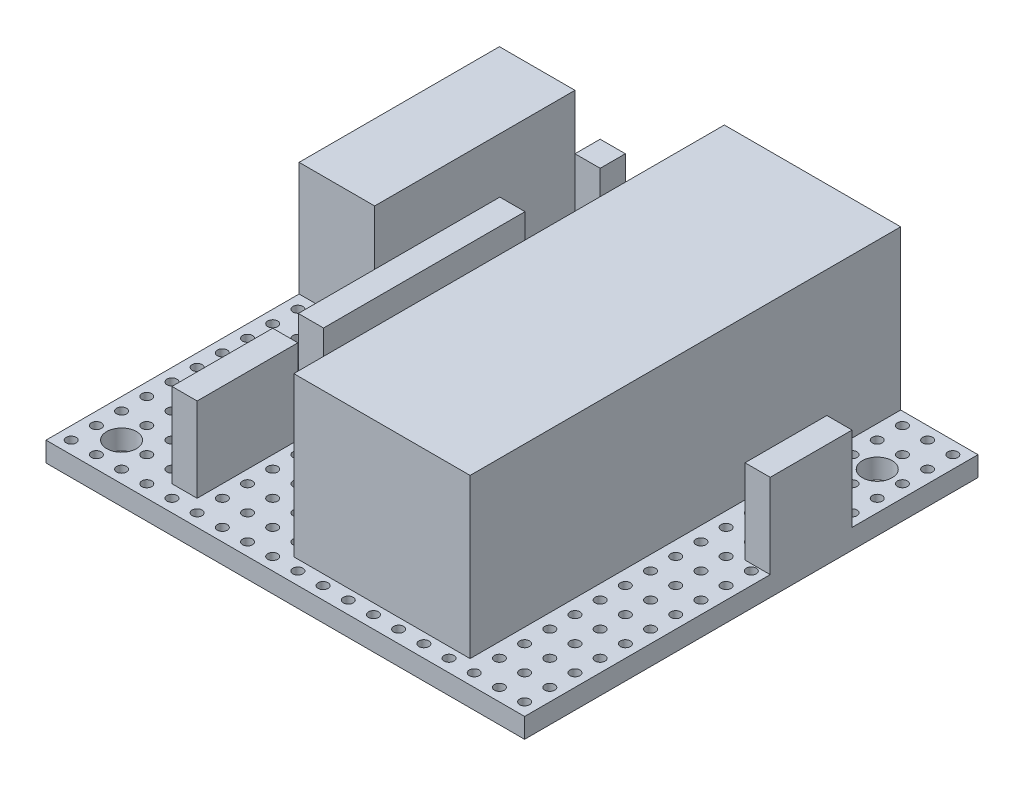
from build123d import *

# Parameters (mm, degrees)
SKETCH1_W               = 63.5
SKETCH1_H               = 45.72
SKETCH1_R               = 0.5
BOSS_EXTRUDE1_DEPTH     = 2
SKETCH4_W               = 15.24
SKETCH4_H               = 45.72
CUT_EXTRUDE1_DEPTH      = 1
CUT_EXTRUDE1_DEPTH_BACK = 3
SKETCH2_W               = 17.78
SKETCH2_H               = 43.418988053
BOSS_EXTRUDE2_DEPTH     = 16
SKETCH3_W               = 7.62
SKETCH3_H               = 20.2
BOSS_EXTRUDE3_DEPTH     = 11.5
SKETCH5_R               = 1.5
CUT_EXTRUDE2_DEPTH      = 17
CUT_EXTRUDE2_DEPTH_BACK = 3
SKETCH6_W               = 2.54
SKETCH6_H               = 10.16
SKETCH6_H_2             = 20.32
SKETCH6_H_3             = 2.54
SKETCH6_H_4             = 8.253316926
BOSS_EXTRUDE4_DEPTH     = 8.5


with BuildPart() as part:
    # Sketch1 → Boss-Extrude1 (new body)
    with BuildSketch(Plane(origin=(0, 0, 0), x_dir=(1, 0, 0), z_dir=(0, 1, 0))):
        with Locations((3.117422517, -7.111917277)):
            Rectangle(SKETCH1_W, SKETCH1_H)
        with Locations((33.597422517, -28.701917277)):
            Circle(SKETCH1_R, mode=Mode.SUBTRACT)
        with Locations((31.057422517, -28.701917277)):
            Circle(SKETCH1_R, mode=Mode.SUBTRACT)
        with Locations((28.517422517, -28.701917277)):
            Circle(SKETCH1_R, mode=Mode.SUBTRACT)
        with Locations((25.977422517, -28.701917277)):
            Circle(SKETCH1_R, mode=Mode.SUBTRACT)
        with Locations((23.437422517, -28.701917277)):
            Circle(SKETCH1_R, mode=Mode.SUBTRACT)
        with Locations((20.897422517, -28.701917277)):
            Circle(SKETCH1_R, mode=Mode.SUBTRACT)
        with Locations((18.357422517, -28.701917277)):
            Circle(SKETCH1_R, mode=Mode.SUBTRACT)
        with Locations((15.817422517, -28.701917277)):
            Circle(SKETCH1_R, mode=Mode.SUBTRACT)
        with Locations((13.277422517, -28.701917277)):
            Circle(SKETCH1_R, mode=Mode.SUBTRACT)
        with Locations((10.737422517, -28.701917277)):
            Circle(SKETCH1_R, mode=Mode.SUBTRACT)
        with Locations((8.197422517, -28.701917277)):
            Circle(SKETCH1_R, mode=Mode.SUBTRACT)
        with Locations((5.657422517, -28.701917277)):
            Circle(SKETCH1_R, mode=Mode.SUBTRACT)
        with Locations((3.117422517, -28.701917277)):
            Circle(SKETCH1_R, mode=Mode.SUBTRACT)
        with Locations((0.577422517, -28.701917277)):
            Circle(SKETCH1_R, mode=Mode.SUBTRACT)
        with Locations((-1.962577483, -28.701917277)):
            Circle(SKETCH1_R, mode=Mode.SUBTRACT)
        with Locations((-4.502577483, -28.701917277)):
            Circle(SKETCH1_R, mode=Mode.SUBTRACT)
        with Locations((-7.042577483, -28.701917277)):
            Circle(SKETCH1_R, mode=Mode.SUBTRACT)
        with Locations((-9.582577483, -28.701917277)):
            Circle(SKETCH1_R, mode=Mode.SUBTRACT)
        with Locations((-12.122577483, -28.701917277)):
            Circle(SKETCH1_R, mode=Mode.SUBTRACT)
        with Locations((-14.662577483, -28.701917277)):
            Circle(SKETCH1_R, mode=Mode.SUBTRACT)
        with Locations((-17.202577483, -28.701917277)):
            Circle(SKETCH1_R, mode=Mode.SUBTRACT)
        with Locations((-19.742577483, -28.701917277)):
            Circle(SKETCH1_R, mode=Mode.SUBTRACT)
        with Locations((-22.282577483, -28.701917277)):
            Circle(SKETCH1_R, mode=Mode.SUBTRACT)
        with Locations((-24.822577483, -28.701917277)):
            Circle(SKETCH1_R, mode=Mode.SUBTRACT)
        with Locations((-27.362577483, -28.701917277)):
            Circle(SKETCH1_R, mode=Mode.SUBTRACT)
        with Locations((31.057422517, -26.161917277)):
            Circle(SKETCH1_R, mode=Mode.SUBTRACT)
        with Locations((28.517422517, -26.161917277)):
            Circle(SKETCH1_R, mode=Mode.SUBTRACT)
        with Locations((25.977422517, -26.161917277)):
            Circle(SKETCH1_R, mode=Mode.SUBTRACT)
        with Locations((23.437422517, -26.161917277)):
            Circle(SKETCH1_R, mode=Mode.SUBTRACT)
        with Locations((20.897422517, -26.161917277)):
            Circle(SKETCH1_R, mode=Mode.SUBTRACT)
        with Locations((18.357422517, -26.161917277)):
            Circle(SKETCH1_R, mode=Mode.SUBTRACT)
        with Locations((15.817422517, -26.161917277)):
            Circle(SKETCH1_R, mode=Mode.SUBTRACT)
        with Locations((13.277422517, -26.161917277)):
            Circle(SKETCH1_R, mode=Mode.SUBTRACT)
        with Locations((10.737422517, -26.161917277)):
            Circle(SKETCH1_R, mode=Mode.SUBTRACT)
        with Locations((8.197422517, -26.161917277)):
            Circle(SKETCH1_R, mode=Mode.SUBTRACT)
        with Locations((5.657422517, -26.161917277)):
            Circle(SKETCH1_R, mode=Mode.SUBTRACT)
        with Locations((3.117422517, -26.161917277)):
            Circle(SKETCH1_R, mode=Mode.SUBTRACT)
        with Locations((0.577422517, -26.161917277)):
            Circle(SKETCH1_R, mode=Mode.SUBTRACT)
        with Locations((-1.962577483, -26.161917277)):
            Circle(SKETCH1_R, mode=Mode.SUBTRACT)
        with Locations((-4.502577483, -26.161917277)):
            Circle(SKETCH1_R, mode=Mode.SUBTRACT)
        with Locations((-7.042577483, -26.161917277)):
            Circle(SKETCH1_R, mode=Mode.SUBTRACT)
        with Locations((-9.582577483, -26.161917277)):
            Circle(SKETCH1_R, mode=Mode.SUBTRACT)
        with Locations((-12.122577483, -26.161917277)):
            Circle(SKETCH1_R, mode=Mode.SUBTRACT)
        with Locations((-14.662577483, -26.161917277)):
            Circle(SKETCH1_R, mode=Mode.SUBTRACT)
        with Locations((-17.202577483, -26.161917277)):
            Circle(SKETCH1_R, mode=Mode.SUBTRACT)
        with Locations((-19.742577483, -26.161917277)):
            Circle(SKETCH1_R, mode=Mode.SUBTRACT)
        with Locations((-22.282577483, -26.161917277)):
            Circle(SKETCH1_R, mode=Mode.SUBTRACT)
        with Locations((-24.822577483, -26.161917277)):
            Circle(SKETCH1_R, mode=Mode.SUBTRACT)
        with Locations((-27.362577483, -26.161917277)):
            Circle(SKETCH1_R, mode=Mode.SUBTRACT)
        with Locations((31.057422517, -23.621917277)):
            Circle(SKETCH1_R, mode=Mode.SUBTRACT)
        with Locations((28.517422517, -23.621917277)):
            Circle(SKETCH1_R, mode=Mode.SUBTRACT)
        with Locations((25.977422517, -23.621917277)):
            Circle(SKETCH1_R, mode=Mode.SUBTRACT)
        with Locations((23.437422517, -23.621917277)):
            Circle(SKETCH1_R, mode=Mode.SUBTRACT)
        with Locations((20.897422517, -23.621917277)):
            Circle(SKETCH1_R, mode=Mode.SUBTRACT)
        with Locations((18.357422517, -23.621917277)):
            Circle(SKETCH1_R, mode=Mode.SUBTRACT)
        with Locations((15.817422517, -23.621917277)):
            Circle(SKETCH1_R, mode=Mode.SUBTRACT)
        with Locations((13.277422517, -23.621917277)):
            Circle(SKETCH1_R, mode=Mode.SUBTRACT)
        with Locations((10.737422517, -23.621917277)):
            Circle(SKETCH1_R, mode=Mode.SUBTRACT)
        with Locations((8.197422517, -23.621917277)):
            Circle(SKETCH1_R, mode=Mode.SUBTRACT)
        with Locations((5.657422517, -23.621917277)):
            Circle(SKETCH1_R, mode=Mode.SUBTRACT)
        with Locations((3.117422517, -23.621917277)):
            Circle(SKETCH1_R, mode=Mode.SUBTRACT)
        with Locations((0.577422517, -23.621917277)):
            Circle(SKETCH1_R, mode=Mode.SUBTRACT)
        with Locations((-1.962577483, -23.621917277)):
            Circle(SKETCH1_R, mode=Mode.SUBTRACT)
        with Locations((-4.502577483, -23.621917277)):
            Circle(SKETCH1_R, mode=Mode.SUBTRACT)
        with Locations((-7.042577483, -23.621917277)):
            Circle(SKETCH1_R, mode=Mode.SUBTRACT)
        with Locations((-9.582577483, -23.621917277)):
            Circle(SKETCH1_R, mode=Mode.SUBTRACT)
        with Locations((-12.122577483, -23.621917277)):
            Circle(SKETCH1_R, mode=Mode.SUBTRACT)
        with Locations((-14.662577483, -23.621917277)):
            Circle(SKETCH1_R, mode=Mode.SUBTRACT)
        with Locations((-17.202577483, -23.621917277)):
            Circle(SKETCH1_R, mode=Mode.SUBTRACT)
        with Locations((-19.742577483, -23.621917277)):
            Circle(SKETCH1_R, mode=Mode.SUBTRACT)
        with Locations((-22.282577483, -23.621917277)):
            Circle(SKETCH1_R, mode=Mode.SUBTRACT)
        with Locations((-24.822577483, -23.621917277)):
            Circle(SKETCH1_R, mode=Mode.SUBTRACT)
        with Locations((-27.362577483, -23.621917277)):
            Circle(SKETCH1_R, mode=Mode.SUBTRACT)
        with Locations((31.057422517, -21.081917277)):
            Circle(SKETCH1_R, mode=Mode.SUBTRACT)
        with Locations((28.517422517, -21.081917277)):
            Circle(SKETCH1_R, mode=Mode.SUBTRACT)
        with Locations((25.977422517, -21.081917277)):
            Circle(SKETCH1_R, mode=Mode.SUBTRACT)
        with Locations((23.437422517, -21.081917277)):
            Circle(SKETCH1_R, mode=Mode.SUBTRACT)
        with Locations((20.897422517, -21.081917277)):
            Circle(SKETCH1_R, mode=Mode.SUBTRACT)
        with Locations((18.357422517, -21.081917277)):
            Circle(SKETCH1_R, mode=Mode.SUBTRACT)
        with Locations((15.817422517, -21.081917277)):
            Circle(SKETCH1_R, mode=Mode.SUBTRACT)
        with Locations((13.277422517, -21.081917277)):
            Circle(SKETCH1_R, mode=Mode.SUBTRACT)
        with Locations((10.737422517, -21.081917277)):
            Circle(SKETCH1_R, mode=Mode.SUBTRACT)
        with Locations((8.197422517, -21.081917277)):
            Circle(SKETCH1_R, mode=Mode.SUBTRACT)
        with Locations((5.657422517, -21.081917277)):
            Circle(SKETCH1_R, mode=Mode.SUBTRACT)
        with Locations((3.117422517, -21.081917277)):
            Circle(SKETCH1_R, mode=Mode.SUBTRACT)
        with Locations((0.577422517, -21.081917277)):
            Circle(SKETCH1_R, mode=Mode.SUBTRACT)
        with Locations((-1.962577483, -21.081917277)):
            Circle(SKETCH1_R, mode=Mode.SUBTRACT)
        with Locations((-4.502577483, -21.081917277)):
            Circle(SKETCH1_R, mode=Mode.SUBTRACT)
        with Locations((-7.042577483, -21.081917277)):
            Circle(SKETCH1_R, mode=Mode.SUBTRACT)
        with Locations((-9.582577483, -21.081917277)):
            Circle(SKETCH1_R, mode=Mode.SUBTRACT)
        with Locations((-12.122577483, -21.081917277)):
            Circle(SKETCH1_R, mode=Mode.SUBTRACT)
        with Locations((-14.662577483, -21.081917277)):
            Circle(SKETCH1_R, mode=Mode.SUBTRACT)
        with Locations((-17.202577483, -21.081917277)):
            Circle(SKETCH1_R, mode=Mode.SUBTRACT)
        with Locations((-19.742577483, -21.081917277)):
            Circle(SKETCH1_R, mode=Mode.SUBTRACT)
        with Locations((-22.282577483, -21.081917277)):
            Circle(SKETCH1_R, mode=Mode.SUBTRACT)
        with Locations((-24.822577483, -21.081917277)):
            Circle(SKETCH1_R, mode=Mode.SUBTRACT)
        with Locations((-27.362577483, -21.081917277)):
            Circle(SKETCH1_R, mode=Mode.SUBTRACT)
        with Locations((31.057422517, -18.541917277)):
            Circle(SKETCH1_R, mode=Mode.SUBTRACT)
        with Locations((28.517422517, -18.541917277)):
            Circle(SKETCH1_R, mode=Mode.SUBTRACT)
        with Locations((25.977422517, -18.541917277)):
            Circle(SKETCH1_R, mode=Mode.SUBTRACT)
        with Locations((23.437422517, -18.541917277)):
            Circle(SKETCH1_R, mode=Mode.SUBTRACT)
        with Locations((20.897422517, -18.541917277)):
            Circle(SKETCH1_R, mode=Mode.SUBTRACT)
        with Locations((18.357422517, -18.541917277)):
            Circle(SKETCH1_R, mode=Mode.SUBTRACT)
        with Locations((15.817422517, -18.541917277)):
            Circle(SKETCH1_R, mode=Mode.SUBTRACT)
        with Locations((13.277422517, -18.541917277)):
            Circle(SKETCH1_R, mode=Mode.SUBTRACT)
        with Locations((10.737422517, -18.541917277)):
            Circle(SKETCH1_R, mode=Mode.SUBTRACT)
        with Locations((8.197422517, -18.541917277)):
            Circle(SKETCH1_R, mode=Mode.SUBTRACT)
        with Locations((5.657422517, -18.541917277)):
            Circle(SKETCH1_R, mode=Mode.SUBTRACT)
        with Locations((3.117422517, -18.541917277)):
            Circle(SKETCH1_R, mode=Mode.SUBTRACT)
        with Locations((0.577422517, -18.541917277)):
            Circle(SKETCH1_R, mode=Mode.SUBTRACT)
        with Locations((-1.962577483, -18.541917277)):
            Circle(SKETCH1_R, mode=Mode.SUBTRACT)
        with Locations((-4.502577483, -18.541917277)):
            Circle(SKETCH1_R, mode=Mode.SUBTRACT)
        with Locations((-7.042577483, -18.541917277)):
            Circle(SKETCH1_R, mode=Mode.SUBTRACT)
        with Locations((-9.582577483, -18.541917277)):
            Circle(SKETCH1_R, mode=Mode.SUBTRACT)
        with Locations((-12.122577483, -18.541917277)):
            Circle(SKETCH1_R, mode=Mode.SUBTRACT)
        with Locations((-14.662577483, -18.541917277)):
            Circle(SKETCH1_R, mode=Mode.SUBTRACT)
        with Locations((-17.202577483, -18.541917277)):
            Circle(SKETCH1_R, mode=Mode.SUBTRACT)
        with Locations((-19.742577483, -18.541917277)):
            Circle(SKETCH1_R, mode=Mode.SUBTRACT)
        with Locations((-22.282577483, -18.541917277)):
            Circle(SKETCH1_R, mode=Mode.SUBTRACT)
        with Locations((-24.822577483, -18.541917277)):
            Circle(SKETCH1_R, mode=Mode.SUBTRACT)
        with Locations((-27.362577483, -18.541917277)):
            Circle(SKETCH1_R, mode=Mode.SUBTRACT)
        with Locations((31.057422517, -16.001917277)):
            Circle(SKETCH1_R, mode=Mode.SUBTRACT)
        with Locations((28.517422517, -16.001917277)):
            Circle(SKETCH1_R, mode=Mode.SUBTRACT)
        with Locations((25.977422517, -16.001917277)):
            Circle(SKETCH1_R, mode=Mode.SUBTRACT)
        with Locations((23.437422517, -16.001917277)):
            Circle(SKETCH1_R, mode=Mode.SUBTRACT)
        with Locations((20.897422517, -16.001917277)):
            Circle(SKETCH1_R, mode=Mode.SUBTRACT)
        with Locations((18.357422517, -16.001917277)):
            Circle(SKETCH1_R, mode=Mode.SUBTRACT)
        with Locations((15.817422517, -16.001917277)):
            Circle(SKETCH1_R, mode=Mode.SUBTRACT)
        with Locations((13.277422517, -16.001917277)):
            Circle(SKETCH1_R, mode=Mode.SUBTRACT)
        with Locations((10.737422517, -16.001917277)):
            Circle(SKETCH1_R, mode=Mode.SUBTRACT)
        with Locations((8.197422517, -16.001917277)):
            Circle(SKETCH1_R, mode=Mode.SUBTRACT)
        with Locations((5.657422517, -16.001917277)):
            Circle(SKETCH1_R, mode=Mode.SUBTRACT)
        with Locations((3.117422517, -16.001917277)):
            Circle(SKETCH1_R, mode=Mode.SUBTRACT)
        with Locations((0.577422517, -16.001917277)):
            Circle(SKETCH1_R, mode=Mode.SUBTRACT)
        with Locations((-1.962577483, -16.001917277)):
            Circle(SKETCH1_R, mode=Mode.SUBTRACT)
        with Locations((-4.502577483, -16.001917277)):
            Circle(SKETCH1_R, mode=Mode.SUBTRACT)
        with Locations((-7.042577483, -16.001917277)):
            Circle(SKETCH1_R, mode=Mode.SUBTRACT)
        with Locations((-9.582577483, -16.001917277)):
            Circle(SKETCH1_R, mode=Mode.SUBTRACT)
        with Locations((-12.122577483, -16.001917277)):
            Circle(SKETCH1_R, mode=Mode.SUBTRACT)
        with Locations((-14.662577483, -16.001917277)):
            Circle(SKETCH1_R, mode=Mode.SUBTRACT)
        with Locations((-17.202577483, -16.001917277)):
            Circle(SKETCH1_R, mode=Mode.SUBTRACT)
        with Locations((-19.742577483, -16.001917277)):
            Circle(SKETCH1_R, mode=Mode.SUBTRACT)
        with Locations((-22.282577483, -16.001917277)):
            Circle(SKETCH1_R, mode=Mode.SUBTRACT)
        with Locations((-24.822577483, -16.001917277)):
            Circle(SKETCH1_R, mode=Mode.SUBTRACT)
        with Locations((-27.362577483, -16.001917277)):
            Circle(SKETCH1_R, mode=Mode.SUBTRACT)
        with Locations((31.057422517, -13.461917277)):
            Circle(SKETCH1_R, mode=Mode.SUBTRACT)
        with Locations((28.517422517, -13.461917277)):
            Circle(SKETCH1_R, mode=Mode.SUBTRACT)
        with Locations((25.977422517, -13.461917277)):
            Circle(SKETCH1_R, mode=Mode.SUBTRACT)
        with Locations((23.437422517, -13.461917277)):
            Circle(SKETCH1_R, mode=Mode.SUBTRACT)
        with Locations((20.897422517, -13.461917277)):
            Circle(SKETCH1_R, mode=Mode.SUBTRACT)
        with Locations((18.357422517, -13.461917277)):
            Circle(SKETCH1_R, mode=Mode.SUBTRACT)
        with Locations((15.817422517, -13.461917277)):
            Circle(SKETCH1_R, mode=Mode.SUBTRACT)
        with Locations((13.277422517, -13.461917277)):
            Circle(SKETCH1_R, mode=Mode.SUBTRACT)
        with Locations((10.737422517, -13.461917277)):
            Circle(SKETCH1_R, mode=Mode.SUBTRACT)
        with Locations((8.197422517, -13.461917277)):
            Circle(SKETCH1_R, mode=Mode.SUBTRACT)
        with Locations((5.657422517, -13.461917277)):
            Circle(SKETCH1_R, mode=Mode.SUBTRACT)
        with Locations((3.117422517, -13.461917277)):
            Circle(SKETCH1_R, mode=Mode.SUBTRACT)
        with Locations((0.577422517, -13.461917277)):
            Circle(SKETCH1_R, mode=Mode.SUBTRACT)
        with Locations((-1.962577483, -13.461917277)):
            Circle(SKETCH1_R, mode=Mode.SUBTRACT)
        with Locations((-4.502577483, -13.461917277)):
            Circle(SKETCH1_R, mode=Mode.SUBTRACT)
        with Locations((-7.042577483, -13.461917277)):
            Circle(SKETCH1_R, mode=Mode.SUBTRACT)
        with Locations((-9.582577483, -13.461917277)):
            Circle(SKETCH1_R, mode=Mode.SUBTRACT)
        with Locations((-12.122577483, -13.461917277)):
            Circle(SKETCH1_R, mode=Mode.SUBTRACT)
        with Locations((-14.662577483, -13.461917277)):
            Circle(SKETCH1_R, mode=Mode.SUBTRACT)
        with Locations((-17.202577483, -13.461917277)):
            Circle(SKETCH1_R, mode=Mode.SUBTRACT)
        with Locations((-19.742577483, -13.461917277)):
            Circle(SKETCH1_R, mode=Mode.SUBTRACT)
        with Locations((-22.282577483, -13.461917277)):
            Circle(SKETCH1_R, mode=Mode.SUBTRACT)
        with Locations((-24.822577483, -13.461917277)):
            Circle(SKETCH1_R, mode=Mode.SUBTRACT)
        with Locations((-27.362577483, -13.461917277)):
            Circle(SKETCH1_R, mode=Mode.SUBTRACT)
        with Locations((31.057422517, -10.921917277)):
            Circle(SKETCH1_R, mode=Mode.SUBTRACT)
        with Locations((28.517422517, -10.921917277)):
            Circle(SKETCH1_R, mode=Mode.SUBTRACT)
        with Locations((25.977422517, -10.921917277)):
            Circle(SKETCH1_R, mode=Mode.SUBTRACT)
        with Locations((23.437422517, -10.921917277)):
            Circle(SKETCH1_R, mode=Mode.SUBTRACT)
        with Locations((20.897422517, -10.921917277)):
            Circle(SKETCH1_R, mode=Mode.SUBTRACT)
        with Locations((18.357422517, -10.921917277)):
            Circle(SKETCH1_R, mode=Mode.SUBTRACT)
        with Locations((15.817422517, -10.921917277)):
            Circle(SKETCH1_R, mode=Mode.SUBTRACT)
        with Locations((13.277422517, -10.921917277)):
            Circle(SKETCH1_R, mode=Mode.SUBTRACT)
        with Locations((10.737422517, -10.921917277)):
            Circle(SKETCH1_R, mode=Mode.SUBTRACT)
        with Locations((8.197422517, -10.921917277)):
            Circle(SKETCH1_R, mode=Mode.SUBTRACT)
        with Locations((5.657422517, -10.921917277)):
            Circle(SKETCH1_R, mode=Mode.SUBTRACT)
        with Locations((3.117422517, -10.921917277)):
            Circle(SKETCH1_R, mode=Mode.SUBTRACT)
        with Locations((0.577422517, -10.921917277)):
            Circle(SKETCH1_R, mode=Mode.SUBTRACT)
        with Locations((-1.962577483, -10.921917277)):
            Circle(SKETCH1_R, mode=Mode.SUBTRACT)
        with Locations((-4.502577483, -10.921917277)):
            Circle(SKETCH1_R, mode=Mode.SUBTRACT)
        with Locations((-7.042577483, -10.921917277)):
            Circle(SKETCH1_R, mode=Mode.SUBTRACT)
        with Locations((-9.582577483, -10.921917277)):
            Circle(SKETCH1_R, mode=Mode.SUBTRACT)
        with Locations((-12.122577483, -10.921917277)):
            Circle(SKETCH1_R, mode=Mode.SUBTRACT)
        with Locations((-14.662577483, -10.921917277)):
            Circle(SKETCH1_R, mode=Mode.SUBTRACT)
        with Locations((-17.202577483, -10.921917277)):
            Circle(SKETCH1_R, mode=Mode.SUBTRACT)
        with Locations((-19.742577483, -10.921917277)):
            Circle(SKETCH1_R, mode=Mode.SUBTRACT)
        with Locations((-22.282577483, -10.921917277)):
            Circle(SKETCH1_R, mode=Mode.SUBTRACT)
        with Locations((-24.822577483, -10.921917277)):
            Circle(SKETCH1_R, mode=Mode.SUBTRACT)
        with Locations((-27.362577483, -10.921917277)):
            Circle(SKETCH1_R, mode=Mode.SUBTRACT)
        with Locations((31.057422517, -8.381917277)):
            Circle(SKETCH1_R, mode=Mode.SUBTRACT)
        with Locations((28.517422517, -8.381917277)):
            Circle(SKETCH1_R, mode=Mode.SUBTRACT)
        with Locations((25.977422517, -8.381917277)):
            Circle(SKETCH1_R, mode=Mode.SUBTRACT)
        with Locations((23.437422517, -8.381917277)):
            Circle(SKETCH1_R, mode=Mode.SUBTRACT)
        with Locations((20.897422517, -8.381917277)):
            Circle(SKETCH1_R, mode=Mode.SUBTRACT)
        with Locations((18.357422517, -8.381917277)):
            Circle(SKETCH1_R, mode=Mode.SUBTRACT)
        with Locations((15.817422517, -8.381917277)):
            Circle(SKETCH1_R, mode=Mode.SUBTRACT)
        with Locations((13.277422517, -8.381917277)):
            Circle(SKETCH1_R, mode=Mode.SUBTRACT)
        with Locations((10.737422517, -8.381917277)):
            Circle(SKETCH1_R, mode=Mode.SUBTRACT)
        with Locations((8.197422517, -8.381917277)):
            Circle(SKETCH1_R, mode=Mode.SUBTRACT)
        with Locations((5.657422517, -8.381917277)):
            Circle(SKETCH1_R, mode=Mode.SUBTRACT)
        with Locations((3.117422517, -8.381917277)):
            Circle(SKETCH1_R, mode=Mode.SUBTRACT)
        with Locations((0.577422517, -8.381917277)):
            Circle(SKETCH1_R, mode=Mode.SUBTRACT)
        with Locations((-1.962577483, -8.381917277)):
            Circle(SKETCH1_R, mode=Mode.SUBTRACT)
        with Locations((-4.502577483, -8.381917277)):
            Circle(SKETCH1_R, mode=Mode.SUBTRACT)
        with Locations((-7.042577483, -8.381917277)):
            Circle(SKETCH1_R, mode=Mode.SUBTRACT)
        with Locations((-9.582577483, -8.381917277)):
            Circle(SKETCH1_R, mode=Mode.SUBTRACT)
        with Locations((-12.122577483, -8.381917277)):
            Circle(SKETCH1_R, mode=Mode.SUBTRACT)
        with Locations((-14.662577483, -8.381917277)):
            Circle(SKETCH1_R, mode=Mode.SUBTRACT)
        with Locations((-17.202577483, -8.381917277)):
            Circle(SKETCH1_R, mode=Mode.SUBTRACT)
        with Locations((-19.742577483, -8.381917277)):
            Circle(SKETCH1_R, mode=Mode.SUBTRACT)
        with Locations((-22.282577483, -8.381917277)):
            Circle(SKETCH1_R, mode=Mode.SUBTRACT)
        with Locations((-24.822577483, -8.381917277)):
            Circle(SKETCH1_R, mode=Mode.SUBTRACT)
        with Locations((-27.362577483, -8.381917277)):
            Circle(SKETCH1_R, mode=Mode.SUBTRACT)
        with Locations((31.057422517, -5.841917277)):
            Circle(SKETCH1_R, mode=Mode.SUBTRACT)
        with Locations((28.517422517, -5.841917277)):
            Circle(SKETCH1_R, mode=Mode.SUBTRACT)
        with Locations((25.977422517, -5.841917277)):
            Circle(SKETCH1_R, mode=Mode.SUBTRACT)
        with Locations((23.437422517, -5.841917277)):
            Circle(SKETCH1_R, mode=Mode.SUBTRACT)
        with Locations((20.897422517, -5.841917277)):
            Circle(SKETCH1_R, mode=Mode.SUBTRACT)
        with Locations((18.357422517, -5.841917277)):
            Circle(SKETCH1_R, mode=Mode.SUBTRACT)
        with Locations((15.817422517, -5.841917277)):
            Circle(SKETCH1_R, mode=Mode.SUBTRACT)
        with Locations((13.277422517, -5.841917277)):
            Circle(SKETCH1_R, mode=Mode.SUBTRACT)
        with Locations((10.737422517, -5.841917277)):
            Circle(SKETCH1_R, mode=Mode.SUBTRACT)
        with Locations((8.197422517, -5.841917277)):
            Circle(SKETCH1_R, mode=Mode.SUBTRACT)
        with Locations((5.657422517, -5.841917277)):
            Circle(SKETCH1_R, mode=Mode.SUBTRACT)
        with Locations((3.117422517, -5.841917277)):
            Circle(SKETCH1_R, mode=Mode.SUBTRACT)
        with Locations((0.577422517, -5.841917277)):
            Circle(SKETCH1_R, mode=Mode.SUBTRACT)
        with Locations((-1.962577483, -5.841917277)):
            Circle(SKETCH1_R, mode=Mode.SUBTRACT)
        with Locations((-4.502577483, -5.841917277)):
            Circle(SKETCH1_R, mode=Mode.SUBTRACT)
        with Locations((-7.042577483, -5.841917277)):
            Circle(SKETCH1_R, mode=Mode.SUBTRACT)
        with Locations((-9.582577483, -5.841917277)):
            Circle(SKETCH1_R, mode=Mode.SUBTRACT)
        with Locations((-12.122577483, -5.841917277)):
            Circle(SKETCH1_R, mode=Mode.SUBTRACT)
        with Locations((-14.662577483, -5.841917277)):
            Circle(SKETCH1_R, mode=Mode.SUBTRACT)
        with Locations((-17.202577483, -5.841917277)):
            Circle(SKETCH1_R, mode=Mode.SUBTRACT)
        with Locations((-19.742577483, -5.841917277)):
            Circle(SKETCH1_R, mode=Mode.SUBTRACT)
        with Locations((-22.282577483, -5.841917277)):
            Circle(SKETCH1_R, mode=Mode.SUBTRACT)
        with Locations((-24.822577483, -5.841917277)):
            Circle(SKETCH1_R, mode=Mode.SUBTRACT)
        with Locations((-27.362577483, -5.841917277)):
            Circle(SKETCH1_R, mode=Mode.SUBTRACT)
        with Locations((31.057422517, -3.301917277)):
            Circle(SKETCH1_R, mode=Mode.SUBTRACT)
        with Locations((28.517422517, -3.301917277)):
            Circle(SKETCH1_R, mode=Mode.SUBTRACT)
        with Locations((25.977422517, -3.301917277)):
            Circle(SKETCH1_R, mode=Mode.SUBTRACT)
        with Locations((23.437422517, -3.301917277)):
            Circle(SKETCH1_R, mode=Mode.SUBTRACT)
        with Locations((20.897422517, -3.301917277)):
            Circle(SKETCH1_R, mode=Mode.SUBTRACT)
        with Locations((18.357422517, -3.301917277)):
            Circle(SKETCH1_R, mode=Mode.SUBTRACT)
        with Locations((15.817422517, -3.301917277)):
            Circle(SKETCH1_R, mode=Mode.SUBTRACT)
        with Locations((13.277422517, -3.301917277)):
            Circle(SKETCH1_R, mode=Mode.SUBTRACT)
        with Locations((10.737422517, -3.301917277)):
            Circle(SKETCH1_R, mode=Mode.SUBTRACT)
        with Locations((8.197422517, -3.301917277)):
            Circle(SKETCH1_R, mode=Mode.SUBTRACT)
        with Locations((5.657422517, -3.301917277)):
            Circle(SKETCH1_R, mode=Mode.SUBTRACT)
        with Locations((3.117422517, -3.301917277)):
            Circle(SKETCH1_R, mode=Mode.SUBTRACT)
        with Locations((0.577422517, -3.301917277)):
            Circle(SKETCH1_R, mode=Mode.SUBTRACT)
        with Locations((-1.962577483, -3.301917277)):
            Circle(SKETCH1_R, mode=Mode.SUBTRACT)
        with Locations((-4.502577483, -3.301917277)):
            Circle(SKETCH1_R, mode=Mode.SUBTRACT)
        with Locations((-7.042577483, -3.301917277)):
            Circle(SKETCH1_R, mode=Mode.SUBTRACT)
        with Locations((-9.582577483, -3.301917277)):
            Circle(SKETCH1_R, mode=Mode.SUBTRACT)
        with Locations((-12.122577483, -3.301917277)):
            Circle(SKETCH1_R, mode=Mode.SUBTRACT)
        with Locations((-14.662577483, -3.301917277)):
            Circle(SKETCH1_R, mode=Mode.SUBTRACT)
        with Locations((-17.202577483, -3.301917277)):
            Circle(SKETCH1_R, mode=Mode.SUBTRACT)
        with Locations((-19.742577483, -3.301917277)):
            Circle(SKETCH1_R, mode=Mode.SUBTRACT)
        with Locations((-22.282577483, -3.301917277)):
            Circle(SKETCH1_R, mode=Mode.SUBTRACT)
        with Locations((-24.822577483, -3.301917277)):
            Circle(SKETCH1_R, mode=Mode.SUBTRACT)
        with Locations((-27.362577483, -3.301917277)):
            Circle(SKETCH1_R, mode=Mode.SUBTRACT)
        with Locations((31.057422517, -0.761917277)):
            Circle(SKETCH1_R, mode=Mode.SUBTRACT)
        with Locations((28.517422517, -0.761917277)):
            Circle(SKETCH1_R, mode=Mode.SUBTRACT)
        with Locations((25.977422517, -0.761917277)):
            Circle(SKETCH1_R, mode=Mode.SUBTRACT)
        with Locations((23.437422517, -0.761917277)):
            Circle(SKETCH1_R, mode=Mode.SUBTRACT)
        with Locations((20.897422517, -0.761917277)):
            Circle(SKETCH1_R, mode=Mode.SUBTRACT)
        with Locations((18.357422517, -0.761917277)):
            Circle(SKETCH1_R, mode=Mode.SUBTRACT)
        with Locations((15.817422517, -0.761917277)):
            Circle(SKETCH1_R, mode=Mode.SUBTRACT)
        with Locations((13.277422517, -0.761917277)):
            Circle(SKETCH1_R, mode=Mode.SUBTRACT)
        with Locations((10.737422517, -0.761917277)):
            Circle(SKETCH1_R, mode=Mode.SUBTRACT)
        with Locations((8.197422517, -0.761917277)):
            Circle(SKETCH1_R, mode=Mode.SUBTRACT)
        with Locations((5.657422517, -0.761917277)):
            Circle(SKETCH1_R, mode=Mode.SUBTRACT)
        with Locations((3.117422517, -0.761917277)):
            Circle(SKETCH1_R, mode=Mode.SUBTRACT)
        with Locations((0.577422517, -0.761917277)):
            Circle(SKETCH1_R, mode=Mode.SUBTRACT)
        with Locations((-1.962577483, -0.761917277)):
            Circle(SKETCH1_R, mode=Mode.SUBTRACT)
        with Locations((-4.502577483, -0.761917277)):
            Circle(SKETCH1_R, mode=Mode.SUBTRACT)
        with Locations((-7.042577483, -0.761917277)):
            Circle(SKETCH1_R, mode=Mode.SUBTRACT)
        with Locations((-9.582577483, -0.761917277)):
            Circle(SKETCH1_R, mode=Mode.SUBTRACT)
        with Locations((-12.122577483, -0.761917277)):
            Circle(SKETCH1_R, mode=Mode.SUBTRACT)
        with Locations((-14.662577483, -0.761917277)):
            Circle(SKETCH1_R, mode=Mode.SUBTRACT)
        with Locations((-17.202577483, -0.761917277)):
            Circle(SKETCH1_R, mode=Mode.SUBTRACT)
        with Locations((-19.742577483, -0.761917277)):
            Circle(SKETCH1_R, mode=Mode.SUBTRACT)
        with Locations((-22.282577483, -0.761917277)):
            Circle(SKETCH1_R, mode=Mode.SUBTRACT)
        with Locations((-24.822577483, -0.761917277)):
            Circle(SKETCH1_R, mode=Mode.SUBTRACT)
        with Locations((-27.362577483, -0.761917277)):
            Circle(SKETCH1_R, mode=Mode.SUBTRACT)
        with Locations((31.057422517, 1.778082723)):
            Circle(SKETCH1_R, mode=Mode.SUBTRACT)
        with Locations((28.517422517, 1.778082723)):
            Circle(SKETCH1_R, mode=Mode.SUBTRACT)
        with Locations((25.977422517, 1.778082723)):
            Circle(SKETCH1_R, mode=Mode.SUBTRACT)
        with Locations((23.437422517, 1.778082723)):
            Circle(SKETCH1_R, mode=Mode.SUBTRACT)
        with Locations((20.897422517, 1.778082723)):
            Circle(SKETCH1_R, mode=Mode.SUBTRACT)
        with Locations((18.357422517, 1.778082723)):
            Circle(SKETCH1_R, mode=Mode.SUBTRACT)
        with Locations((15.817422517, 1.778082723)):
            Circle(SKETCH1_R, mode=Mode.SUBTRACT)
        with Locations((13.277422517, 1.778082723)):
            Circle(SKETCH1_R, mode=Mode.SUBTRACT)
        with Locations((10.737422517, 1.778082723)):
            Circle(SKETCH1_R, mode=Mode.SUBTRACT)
        with Locations((8.197422517, 1.778082723)):
            Circle(SKETCH1_R, mode=Mode.SUBTRACT)
        with Locations((5.657422517, 1.778082723)):
            Circle(SKETCH1_R, mode=Mode.SUBTRACT)
        with Locations((3.117422517, 1.778082723)):
            Circle(SKETCH1_R, mode=Mode.SUBTRACT)
        with Locations((0.577422517, 1.778082723)):
            Circle(SKETCH1_R, mode=Mode.SUBTRACT)
        with Locations((-1.962577483, 1.778082723)):
            Circle(SKETCH1_R, mode=Mode.SUBTRACT)
        with Locations((-4.502577483, 1.778082723)):
            Circle(SKETCH1_R, mode=Mode.SUBTRACT)
        with Locations((-7.042577483, 1.778082723)):
            Circle(SKETCH1_R, mode=Mode.SUBTRACT)
        with Locations((-9.582577483, 1.778082723)):
            Circle(SKETCH1_R, mode=Mode.SUBTRACT)
        with Locations((-12.122577483, 1.778082723)):
            Circle(SKETCH1_R, mode=Mode.SUBTRACT)
        with Locations((-14.662577483, 1.778082723)):
            Circle(SKETCH1_R, mode=Mode.SUBTRACT)
        with Locations((-17.202577483, 1.778082723)):
            Circle(SKETCH1_R, mode=Mode.SUBTRACT)
        with Locations((-19.742577483, 1.778082723)):
            Circle(SKETCH1_R, mode=Mode.SUBTRACT)
        with Locations((-22.282577483, 1.778082723)):
            Circle(SKETCH1_R, mode=Mode.SUBTRACT)
        with Locations((-24.822577483, 1.778082723)):
            Circle(SKETCH1_R, mode=Mode.SUBTRACT)
        with Locations((-27.362577483, 1.778082723)):
            Circle(SKETCH1_R, mode=Mode.SUBTRACT)
        with Locations((31.057422517, 4.318082723)):
            Circle(SKETCH1_R, mode=Mode.SUBTRACT)
        with Locations((28.517422517, 4.318082723)):
            Circle(SKETCH1_R, mode=Mode.SUBTRACT)
        with Locations((25.977422517, 4.318082723)):
            Circle(SKETCH1_R, mode=Mode.SUBTRACT)
        with Locations((23.437422517, 4.318082723)):
            Circle(SKETCH1_R, mode=Mode.SUBTRACT)
        with Locations((20.897422517, 4.318082723)):
            Circle(SKETCH1_R, mode=Mode.SUBTRACT)
        with Locations((18.357422517, 4.318082723)):
            Circle(SKETCH1_R, mode=Mode.SUBTRACT)
        with Locations((15.817422517, 4.318082723)):
            Circle(SKETCH1_R, mode=Mode.SUBTRACT)
        with Locations((13.277422517, 4.318082723)):
            Circle(SKETCH1_R, mode=Mode.SUBTRACT)
        with Locations((10.737422517, 4.318082723)):
            Circle(SKETCH1_R, mode=Mode.SUBTRACT)
        with Locations((8.197422517, 4.318082723)):
            Circle(SKETCH1_R, mode=Mode.SUBTRACT)
        with Locations((5.657422517, 4.318082723)):
            Circle(SKETCH1_R, mode=Mode.SUBTRACT)
        with Locations((3.117422517, 4.318082723)):
            Circle(SKETCH1_R, mode=Mode.SUBTRACT)
        with Locations((0.577422517, 4.318082723)):
            Circle(SKETCH1_R, mode=Mode.SUBTRACT)
        with Locations((-1.962577483, 4.318082723)):
            Circle(SKETCH1_R, mode=Mode.SUBTRACT)
        with Locations((-4.502577483, 4.318082723)):
            Circle(SKETCH1_R, mode=Mode.SUBTRACT)
        with Locations((-7.042577483, 4.318082723)):
            Circle(SKETCH1_R, mode=Mode.SUBTRACT)
        with Locations((-9.582577483, 4.318082723)):
            Circle(SKETCH1_R, mode=Mode.SUBTRACT)
        with Locations((-12.122577483, 4.318082723)):
            Circle(SKETCH1_R, mode=Mode.SUBTRACT)
        with Locations((-14.662577483, 4.318082723)):
            Circle(SKETCH1_R, mode=Mode.SUBTRACT)
        with Locations((-17.202577483, 4.318082723)):
            Circle(SKETCH1_R, mode=Mode.SUBTRACT)
        with Locations((-19.742577483, 4.318082723)):
            Circle(SKETCH1_R, mode=Mode.SUBTRACT)
        with Locations((-22.282577483, 4.318082723)):
            Circle(SKETCH1_R, mode=Mode.SUBTRACT)
        with Locations((-24.822577483, 4.318082723)):
            Circle(SKETCH1_R, mode=Mode.SUBTRACT)
        with Locations((-27.362577483, 4.318082723)):
            Circle(SKETCH1_R, mode=Mode.SUBTRACT)
        with Locations((31.057422517, 6.858082723)):
            Circle(SKETCH1_R, mode=Mode.SUBTRACT)
        with Locations((28.517422517, 6.858082723)):
            Circle(SKETCH1_R, mode=Mode.SUBTRACT)
        with Locations((25.977422517, 6.858082723)):
            Circle(SKETCH1_R, mode=Mode.SUBTRACT)
        with Locations((23.437422517, 6.858082723)):
            Circle(SKETCH1_R, mode=Mode.SUBTRACT)
        with Locations((20.897422517, 6.858082723)):
            Circle(SKETCH1_R, mode=Mode.SUBTRACT)
        with Locations((18.357422517, 6.858082723)):
            Circle(SKETCH1_R, mode=Mode.SUBTRACT)
        with Locations((15.817422517, 6.858082723)):
            Circle(SKETCH1_R, mode=Mode.SUBTRACT)
        with Locations((13.277422517, 6.858082723)):
            Circle(SKETCH1_R, mode=Mode.SUBTRACT)
        with Locations((10.737422517, 6.858082723)):
            Circle(SKETCH1_R, mode=Mode.SUBTRACT)
        with Locations((8.197422517, 6.858082723)):
            Circle(SKETCH1_R, mode=Mode.SUBTRACT)
        with Locations((5.657422517, 6.858082723)):
            Circle(SKETCH1_R, mode=Mode.SUBTRACT)
        with Locations((3.117422517, 6.858082723)):
            Circle(SKETCH1_R, mode=Mode.SUBTRACT)
        with Locations((0.577422517, 6.858082723)):
            Circle(SKETCH1_R, mode=Mode.SUBTRACT)
        with Locations((-1.962577483, 6.858082723)):
            Circle(SKETCH1_R, mode=Mode.SUBTRACT)
        with Locations((-4.502577483, 6.858082723)):
            Circle(SKETCH1_R, mode=Mode.SUBTRACT)
        with Locations((-7.042577483, 6.858082723)):
            Circle(SKETCH1_R, mode=Mode.SUBTRACT)
        with Locations((-9.582577483, 6.858082723)):
            Circle(SKETCH1_R, mode=Mode.SUBTRACT)
        with Locations((-12.122577483, 6.858082723)):
            Circle(SKETCH1_R, mode=Mode.SUBTRACT)
        with Locations((-14.662577483, 6.858082723)):
            Circle(SKETCH1_R, mode=Mode.SUBTRACT)
        with Locations((-17.202577483, 6.858082723)):
            Circle(SKETCH1_R, mode=Mode.SUBTRACT)
        with Locations((-19.742577483, 6.858082723)):
            Circle(SKETCH1_R, mode=Mode.SUBTRACT)
        with Locations((-22.282577483, 6.858082723)):
            Circle(SKETCH1_R, mode=Mode.SUBTRACT)
        with Locations((-24.822577483, 6.858082723)):
            Circle(SKETCH1_R, mode=Mode.SUBTRACT)
        with Locations((-27.362577483, 6.858082723)):
            Circle(SKETCH1_R, mode=Mode.SUBTRACT)
        with Locations((31.057422517, 9.398082723)):
            Circle(SKETCH1_R, mode=Mode.SUBTRACT)
        with Locations((28.517422517, 9.398082723)):
            Circle(SKETCH1_R, mode=Mode.SUBTRACT)
        with Locations((25.977422517, 9.398082723)):
            Circle(SKETCH1_R, mode=Mode.SUBTRACT)
        with Locations((23.437422517, 9.398082723)):
            Circle(SKETCH1_R, mode=Mode.SUBTRACT)
        with Locations((20.897422517, 9.398082723)):
            Circle(SKETCH1_R, mode=Mode.SUBTRACT)
        with Locations((18.357422517, 9.398082723)):
            Circle(SKETCH1_R, mode=Mode.SUBTRACT)
        with Locations((15.817422517, 9.398082723)):
            Circle(SKETCH1_R, mode=Mode.SUBTRACT)
        with Locations((13.277422517, 9.398082723)):
            Circle(SKETCH1_R, mode=Mode.SUBTRACT)
        with Locations((10.737422517, 9.398082723)):
            Circle(SKETCH1_R, mode=Mode.SUBTRACT)
        with Locations((8.197422517, 9.398082723)):
            Circle(SKETCH1_R, mode=Mode.SUBTRACT)
        with Locations((5.657422517, 9.398082723)):
            Circle(SKETCH1_R, mode=Mode.SUBTRACT)
        with Locations((3.117422517, 9.398082723)):
            Circle(SKETCH1_R, mode=Mode.SUBTRACT)
        with Locations((0.577422517, 9.398082723)):
            Circle(SKETCH1_R, mode=Mode.SUBTRACT)
        with Locations((-1.962577483, 9.398082723)):
            Circle(SKETCH1_R, mode=Mode.SUBTRACT)
        with Locations((-4.502577483, 9.398082723)):
            Circle(SKETCH1_R, mode=Mode.SUBTRACT)
        with Locations((-7.042577483, 9.398082723)):
            Circle(SKETCH1_R, mode=Mode.SUBTRACT)
        with Locations((-9.582577483, 9.398082723)):
            Circle(SKETCH1_R, mode=Mode.SUBTRACT)
        with Locations((-12.122577483, 9.398082723)):
            Circle(SKETCH1_R, mode=Mode.SUBTRACT)
        with Locations((-14.662577483, 9.398082723)):
            Circle(SKETCH1_R, mode=Mode.SUBTRACT)
        with Locations((-17.202577483, 9.398082723)):
            Circle(SKETCH1_R, mode=Mode.SUBTRACT)
        with Locations((-19.742577483, 9.398082723)):
            Circle(SKETCH1_R, mode=Mode.SUBTRACT)
        with Locations((-22.282577483, 9.398082723)):
            Circle(SKETCH1_R, mode=Mode.SUBTRACT)
        with Locations((-24.822577483, 9.398082723)):
            Circle(SKETCH1_R, mode=Mode.SUBTRACT)
        with Locations((-27.362577483, 9.398082723)):
            Circle(SKETCH1_R, mode=Mode.SUBTRACT)
        with Locations((31.057422517, 11.938082723)):
            Circle(SKETCH1_R, mode=Mode.SUBTRACT)
        with Locations((28.517422517, 11.938082723)):
            Circle(SKETCH1_R, mode=Mode.SUBTRACT)
        with Locations((25.977422517, 11.938082723)):
            Circle(SKETCH1_R, mode=Mode.SUBTRACT)
        with Locations((23.437422517, 11.938082723)):
            Circle(SKETCH1_R, mode=Mode.SUBTRACT)
        with Locations((20.897422517, 11.938082723)):
            Circle(SKETCH1_R, mode=Mode.SUBTRACT)
        with Locations((18.357422517, 11.938082723)):
            Circle(SKETCH1_R, mode=Mode.SUBTRACT)
        with Locations((15.817422517, 11.938082723)):
            Circle(SKETCH1_R, mode=Mode.SUBTRACT)
        with Locations((13.277422517, 11.938082723)):
            Circle(SKETCH1_R, mode=Mode.SUBTRACT)
        with Locations((10.737422517, 11.938082723)):
            Circle(SKETCH1_R, mode=Mode.SUBTRACT)
        with Locations((8.197422517, 11.938082723)):
            Circle(SKETCH1_R, mode=Mode.SUBTRACT)
        with Locations((5.657422517, 11.938082723)):
            Circle(SKETCH1_R, mode=Mode.SUBTRACT)
        with Locations((3.117422517, 11.938082723)):
            Circle(SKETCH1_R, mode=Mode.SUBTRACT)
        with Locations((0.577422517, 11.938082723)):
            Circle(SKETCH1_R, mode=Mode.SUBTRACT)
        with Locations((-1.962577483, 11.938082723)):
            Circle(SKETCH1_R, mode=Mode.SUBTRACT)
        with Locations((-4.502577483, 11.938082723)):
            Circle(SKETCH1_R, mode=Mode.SUBTRACT)
        with Locations((-7.042577483, 11.938082723)):
            Circle(SKETCH1_R, mode=Mode.SUBTRACT)
        with Locations((-9.582577483, 11.938082723)):
            Circle(SKETCH1_R, mode=Mode.SUBTRACT)
        with Locations((-12.122577483, 11.938082723)):
            Circle(SKETCH1_R, mode=Mode.SUBTRACT)
        with Locations((-14.662577483, 11.938082723)):
            Circle(SKETCH1_R, mode=Mode.SUBTRACT)
        with Locations((-17.202577483, 11.938082723)):
            Circle(SKETCH1_R, mode=Mode.SUBTRACT)
        with Locations((-19.742577483, 11.938082723)):
            Circle(SKETCH1_R, mode=Mode.SUBTRACT)
        with Locations((-22.282577483, 11.938082723)):
            Circle(SKETCH1_R, mode=Mode.SUBTRACT)
        with Locations((-24.822577483, 11.938082723)):
            Circle(SKETCH1_R, mode=Mode.SUBTRACT)
        with Locations((-27.362577483, 11.938082723)):
            Circle(SKETCH1_R, mode=Mode.SUBTRACT)
        with Locations((33.597422517, -26.161917277)):
            Circle(SKETCH1_R, mode=Mode.SUBTRACT)
        with Locations((33.597422517, -23.621917277)):
            Circle(SKETCH1_R, mode=Mode.SUBTRACT)
        with Locations((33.597422517, -21.081917277)):
            Circle(SKETCH1_R, mode=Mode.SUBTRACT)
        with Locations((33.597422517, -18.541917277)):
            Circle(SKETCH1_R, mode=Mode.SUBTRACT)
        with Locations((33.597422517, -16.001917277)):
            Circle(SKETCH1_R, mode=Mode.SUBTRACT)
        with Locations((33.597422517, -13.461917277)):
            Circle(SKETCH1_R, mode=Mode.SUBTRACT)
        with Locations((33.597422517, -10.921917277)):
            Circle(SKETCH1_R, mode=Mode.SUBTRACT)
        with Locations((33.597422517, -8.381917277)):
            Circle(SKETCH1_R, mode=Mode.SUBTRACT)
        with Locations((33.597422517, -5.841917277)):
            Circle(SKETCH1_R, mode=Mode.SUBTRACT)
        with Locations((33.597422517, -3.301917277)):
            Circle(SKETCH1_R, mode=Mode.SUBTRACT)
        with Locations((33.597422517, -0.761917277)):
            Circle(SKETCH1_R, mode=Mode.SUBTRACT)
        with Locations((33.597422517, 1.778082723)):
            Circle(SKETCH1_R, mode=Mode.SUBTRACT)
        with Locations((33.597422517, 4.318082723)):
            Circle(SKETCH1_R, mode=Mode.SUBTRACT)
        with Locations((33.597422517, 6.858082723)):
            Circle(SKETCH1_R, mode=Mode.SUBTRACT)
        with Locations((33.597422517, 9.398082723)):
            Circle(SKETCH1_R, mode=Mode.SUBTRACT)
        with Locations((33.597422517, 11.938082723)):
            Circle(SKETCH1_R, mode=Mode.SUBTRACT)
        with Locations((33.597422517, 14.478082723)):
            Circle(SKETCH1_R, mode=Mode.SUBTRACT)
        with Locations((31.057422517, 14.478082723)):
            Circle(SKETCH1_R, mode=Mode.SUBTRACT)
        with Locations((28.517422517, 14.478082723)):
            Circle(SKETCH1_R, mode=Mode.SUBTRACT)
        with Locations((25.977422517, 14.478082723)):
            Circle(SKETCH1_R, mode=Mode.SUBTRACT)
        with Locations((23.437422517, 14.478082723)):
            Circle(SKETCH1_R, mode=Mode.SUBTRACT)
        with Locations((20.897422517, 14.478082723)):
            Circle(SKETCH1_R, mode=Mode.SUBTRACT)
        with Locations((18.357422517, 14.478082723)):
            Circle(SKETCH1_R, mode=Mode.SUBTRACT)
        with Locations((15.817422517, 14.478082723)):
            Circle(SKETCH1_R, mode=Mode.SUBTRACT)
        with Locations((13.277422517, 14.478082723)):
            Circle(SKETCH1_R, mode=Mode.SUBTRACT)
        with Locations((10.737422517, 14.478082723)):
            Circle(SKETCH1_R, mode=Mode.SUBTRACT)
        with Locations((8.197422517, 14.478082723)):
            Circle(SKETCH1_R, mode=Mode.SUBTRACT)
        with Locations((5.657422517, 14.478082723)):
            Circle(SKETCH1_R, mode=Mode.SUBTRACT)
        with Locations((3.117422517, 14.478082723)):
            Circle(SKETCH1_R, mode=Mode.SUBTRACT)
        with Locations((0.577422517, 14.478082723)):
            Circle(SKETCH1_R, mode=Mode.SUBTRACT)
        with Locations((-1.962577483, 14.478082723)):
            Circle(SKETCH1_R, mode=Mode.SUBTRACT)
        with Locations((-4.502577483, 14.478082723)):
            Circle(SKETCH1_R, mode=Mode.SUBTRACT)
        with Locations((-7.042577483, 14.478082723)):
            Circle(SKETCH1_R, mode=Mode.SUBTRACT)
        with Locations((-9.582577483, 14.478082723)):
            Circle(SKETCH1_R, mode=Mode.SUBTRACT)
        with Locations((-12.122577483, 14.478082723)):
            Circle(SKETCH1_R, mode=Mode.SUBTRACT)
        with Locations((-14.662577483, 14.478082723)):
            Circle(SKETCH1_R, mode=Mode.SUBTRACT)
        with Locations((-17.202577483, 14.478082723)):
            Circle(SKETCH1_R, mode=Mode.SUBTRACT)
        with Locations((-19.742577483, 14.478082723)):
            Circle(SKETCH1_R, mode=Mode.SUBTRACT)
        with Locations((-22.282577483, 14.478082723)):
            Circle(SKETCH1_R, mode=Mode.SUBTRACT)
        with Locations((-24.822577483, 14.478082723)):
            Circle(SKETCH1_R, mode=Mode.SUBTRACT)
        with Locations((-27.362577483, 14.478082723)):
            Circle(SKETCH1_R, mode=Mode.SUBTRACT)
    extrude(amount=BOSS_EXTRUDE1_DEPTH)

    # Sketch4 → Cut-Extrude1 (cut, two sides)
    with BuildSketch(Plane(origin=(0, 2, 0), x_dir=(1, 0, 0), z_dir=(0, 1, 0))) as cut_extrude1_sk:
        with Locations((27.247422517, -7.111917277)):
            Rectangle(SKETCH4_W, SKETCH4_H)
    extrude(amount=CUT_EXTRUDE1_DEPTH, mode=Mode.SUBTRACT)
    extrude(cut_extrude1_sk.sketch, amount=-CUT_EXTRUDE1_DEPTH_BACK, mode=Mode.SUBTRACT)

    # Sketch2 → Boss-Extrude2 (add)
    with BuildSketch(Plane(origin=(0, 2, 0), x_dir=(1, 0, 0), z_dir=(0, 1, 0))):
        with Locations((2.941175177, -5.961411303)):
            Rectangle(SKETCH2_W, SKETCH2_H)
    extrude(amount=BOSS_EXTRUDE2_DEPTH)

    # Sketch3 → Boss-Extrude3 (add)
    with BuildSketch(Plane(origin=(0, 2, 0), x_dir=(1, 0, 0), z_dir=(0, 1, 0))):
        with Locations((-24.822577483, 5.648082723)):
            Rectangle(SKETCH3_W, SKETCH3_H)
    extrude(amount=BOSS_EXTRUDE3_DEPTH)

    # Sketch5 → Cut-Extrude2 (cut, two sides)
    with BuildSketch(Plane(origin=(0, 2, 0), x_dir=(1, 0, 0), z_dir=(0, 1, 0))) as cut_extrude2_sk:
        with Locations((-24.822577483, -26.161917277)):
            Circle(SKETCH5_R)
        with Locations((15.817422517, 9.398082723)):
            Circle(SKETCH5_R)
        with Locations((-17.202577483, 9.398082723)):
            Circle(SKETCH5_R)
    extrude(amount=CUT_EXTRUDE2_DEPTH, mode=Mode.SUBTRACT)
    extrude(cut_extrude2_sk.sketch, amount=-CUT_EXTRUDE2_DEPTH_BACK, mode=Mode.SUBTRACT)

    # Sketch6 → Boss-Extrude4 (add)
    with BuildSketch(Plane(origin=(0, 2, 0), x_dir=(1, 0, 0), z_dir=(0, 1, 0))):
        with Locations((-17.202577483, -22.351917277)):
            Rectangle(SKETCH6_W, SKETCH6_H)
        with Locations((-17.202577483, -4.528725848)):
            Rectangle(SKETCH6_W, SKETCH6_H_2)
        with Locations((-17.202577483, 14.478082723)):
            Rectangle(SKETCH6_W, SKETCH6_H_3)
        with Locations((18.357422517, -1.07857574)):
            Rectangle(SKETCH6_W, SKETCH6_H_4)
    extrude(amount=BOSS_EXTRUDE4_DEPTH)


solid = part.part
